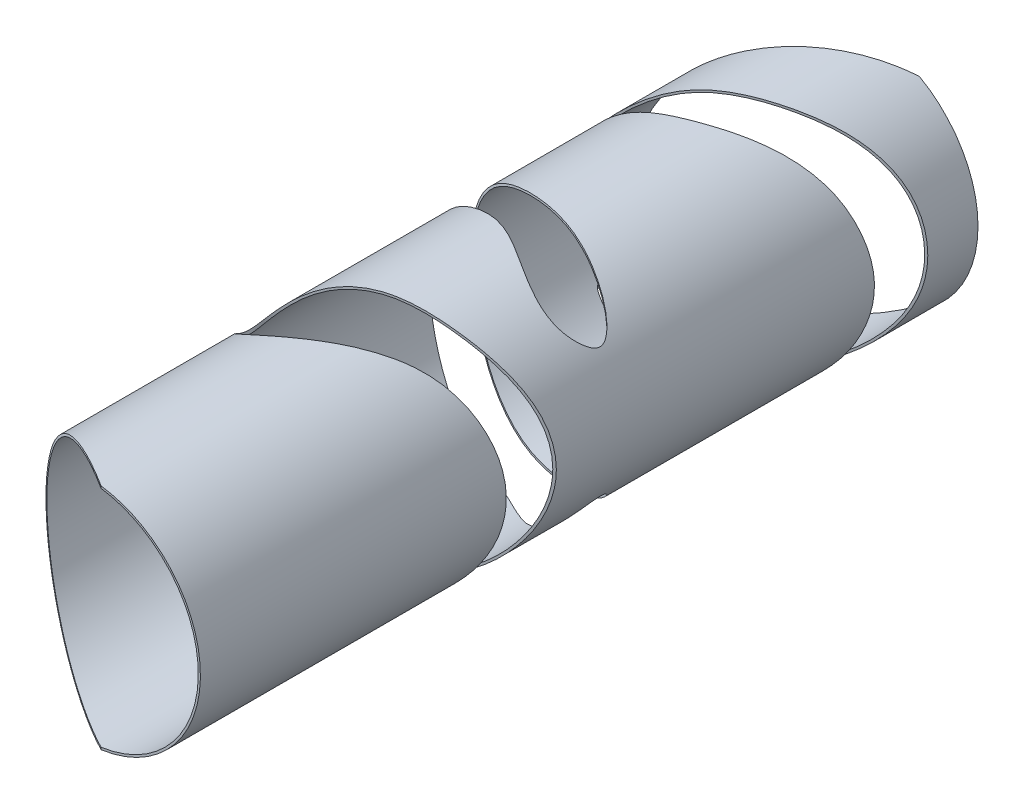
from build123d import *

# Parameters (mm, degrees)
ESQUISSE1_R             = 545.100113617
ESQUISSE1_R_2           = 535.100113617
EXTRU_MINCE1_DEPTH      = 3674
ENL_V_MAT_EXTRU_1_DEPTH = 1514


with BuildPart() as part:
    # Esquisse1 → Extru.-Mince1 (new body)
    with BuildSketch(Plane.XY):
        Circle(ESQUISSE1_R)
        Circle(ESQUISSE1_R_2, mode=Mode.SUBTRACT)
    extrude(amount=-EXTRU_MINCE1_DEPTH)

    # Esquisse2 → Enlèv. mat.-Extru.1 (cut, symmetric)
    with BuildSketch(Plane(origin=(0, 0, 0), x_dir=(1, 0, 0), z_dir=(0, 1, 0))):
        Polygon((-1281.515633999, 2642.32955837), (360.178213435, 3735.121952), (-119.247111821, 4238.50086605), (-1778.117980885, 3368.799517363), align=None)
        with BuildLine():
            add(Edge.make_bspline(
                [(668.876286401, 3418.358667472), (644.386511823, 3546.891799092), (201.567017617, 3192.119650046), (-99.212332843, 3073.506143997), (-288.253005486, 2982.643818685), (-492.574408983, 2827.71156078), (-158.016075215, 2841.27212397), (81.887725096, 2904.260482841), (382.843771995, 3112.828087694), (645.35936564, 3223.468431383), (675.509726975, 3383.543447443), (668.876286401, 3418.358667472)],
                knots=[0, 0, 0, 0, 0.204661304, 0.336785694, 0.439004135, 0.483058465, 0.545666951, 0.678532402, 0.852257295, 0.944564267, 1, 1, 1, 1], degree=3))
        make_face()
        with BuildLine():
            add(Edge.make_bspline(
                [(-854.849520182, 2431.971962177), (-848.647204001, 2510.426902535), (-385.391352132, 2279.391264686), (-71.86562412, 2207.21220302), (241.348474476, 2154.982074417), (491.169925173, 2020.03698881), (344.150623956, 1757.956489401), (31.853861686, 2017.440668843), (-290.845074327, 2066.092781847), (-547.286069879, 2171.276786547), (-766.967295286, 2238.23907065), (-857.960860701, 2392.61569144), (-854.849520182, 2431.971962177)],
                knots=[0, 0, 0, 0, 0.139484981, 0.290600038, 0.413217775, 0.478079392, 0.515299099, 0.65792195, 0.75472904, 0.875846726, 0.930028515, 1, 1, 1, 1], degree=3))
        make_face()
        with BuildLine():
            add(Edge.make_bspline(
                [(906.49111424, 1886.319062096), (895.797294484, 1956.256327486), (343.892985223, 1480.13159745), (27.113769122, 1501.309767798), (-555.009891279, 1313.123947667), (-225.819382423, 845.132064525), (298.399273389, 1396.952056727), (730.09919192, 1480.198713863), (912.056382199, 1849.922373998), (906.49111424, 1886.319062096)],
                knots=[0, 0, 0, 0, 0.146033161, 0.351881282, 0.462784665, 0.526752847, 0.741870735, 0.924001555, 1, 1, 1, 1], degree=3))
        make_face()
        Polygon((-792.979244303, -362.622008072), (-995.756957538, 622.298313356), (259.533648204, -106.735846132), align=None)
    extrude(amount=ENL_V_MAT_EXTRU_1_DEPTH, both=True, mode=Mode.SUBTRACT)


solid = part.part
